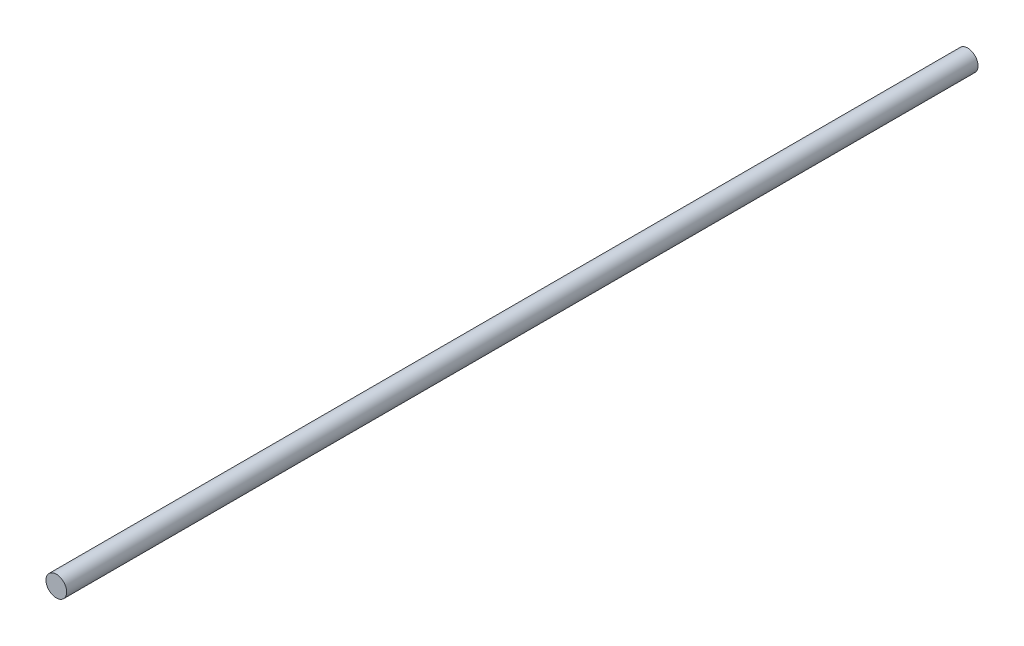
from build123d import *

# Parameters (mm, degrees)
SKETCH1_R           = 3.96875
BOSS_EXTRUDE1_DEPTH = 350


with BuildPart() as part:
    # Sketch1 → Boss-Extrude1 (new body)
    with BuildSketch(Plane.XY):
        Circle(SKETCH1_R)
    extrude(amount=BOSS_EXTRUDE1_DEPTH)


solid = part.part
